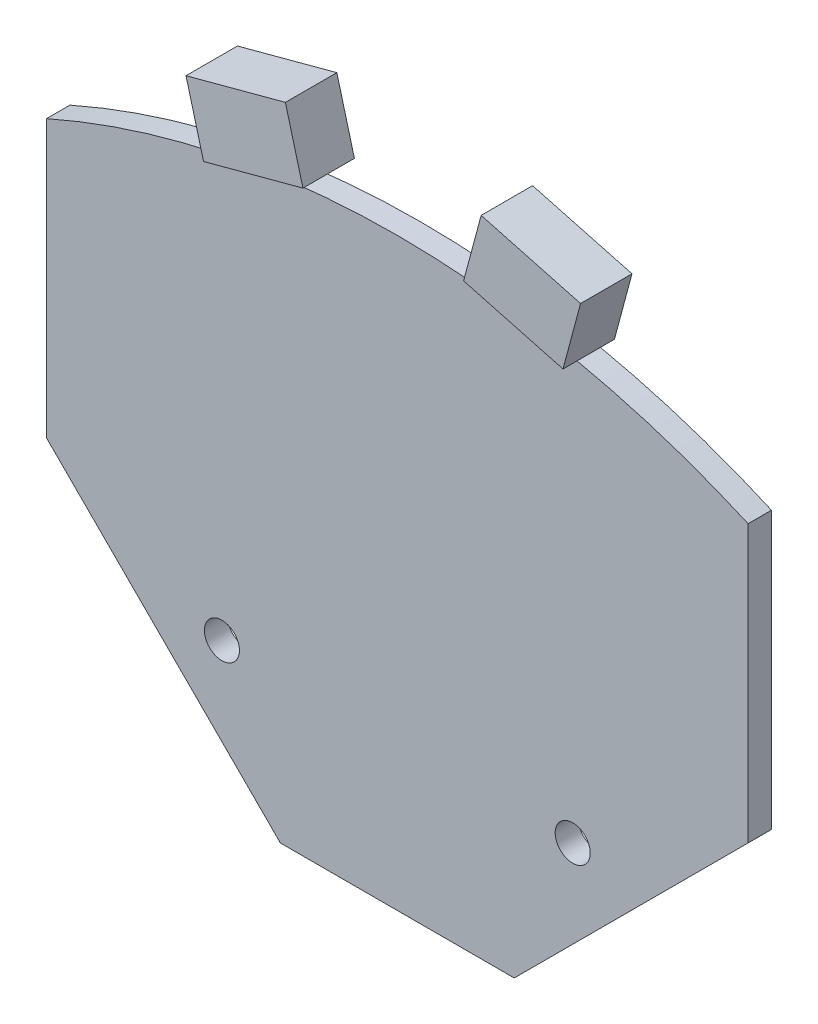
from build123d import *

# Parameters (mm, degrees)
BOSS_EXTRU_1_DEPTH        = 3.2
BOSS_EXTRU_1_DEPTH_BACK   = 1.2
BOSS_EXTRU_1_2_DEPTH      = 3.2
BOSS_EXTRU_1_2_DEPTH_BACK = 1.2
ESQUISSE3_3_R             = 1.5
BOSS_EXTRU_2_DEPTH        = 2


with BuildPart() as part:
    # Esquisse3 → Boss.-Extru.1 (new, two sides: drawn at the far end of the back side and taken through both)
    with BuildSketch(Plane.XY.offset(-BOSS_EXTRU_1_DEPTH_BACK)):
        Polygon((-6.870147271, 53.988790736), (-5.36899681, 48.386420944), (3.131150462, 50.664028541), (1.63, 56.266398333), align=None)
    extrude(amount=BOSS_EXTRU_1_DEPTH + BOSS_EXTRU_1_DEPTH_BACK)


with BuildPart() as body_2:
    # Esquisse3 → Boss.-Extru.1 2 (new, two sides: drawn at the far end of the back side and taken through both)
    with BuildSketch(Plane.XY.offset(-BOSS_EXTRU_1_2_DEPTH_BACK)):
        Polygon((16.868849538, 50.664028541), (25.36899681, 48.386420944), (26.870147271, 53.988790736), (18.37, 56.266398333), align=None)
    extrude(amount=BOSS_EXTRU_1_2_DEPTH + BOSS_EXTRU_1_2_DEPTH_BACK)


with BuildPart() as body_3:
    # Esquisse3_3 → Boss.-Extru.2 (new body)
    with BuildSketch(Plane.XY):
        with BuildLine():
            Line((-20, 43.646138101), (-20, 20))
            Line((-20, 20), (0, 0))
            Line((0, 0), (20, 0))
            Line((20, 0), (40, 20))
            Line((40, 20), (40, 43.646138101))
            ThreePointArc((40, 43.646138101), (32.807981898, 46.397414454), (25.36899681, 48.386420944))
            ThreePointArc((25.36899681, 48.386420944), (10, 50), (-5.36899681, 48.386420944))
            ThreePointArc((-5.36899681, 48.386420944), (-12.807981898, 46.397414454), (-20, 43.646138101))
        make_face()
        with Locations((-5, 12.5)):
            Circle(ESQUISSE3_3_R, mode=Mode.SUBTRACT)
        with Locations((25, 12.5)):
            Circle(ESQUISSE3_3_R, mode=Mode.SUBTRACT)
    extrude(amount=BOSS_EXTRU_2_DEPTH)


solid = Compound([part.part, body_2.part, body_3.part])
